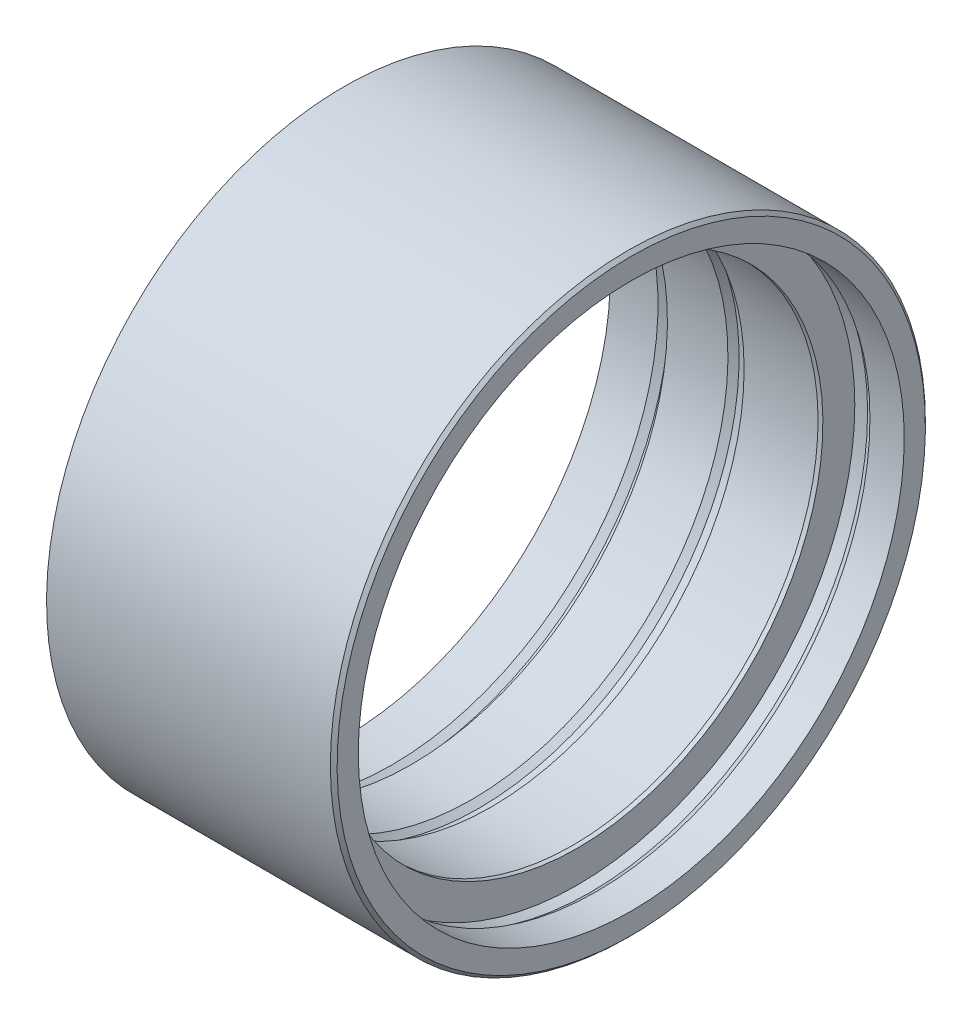
from build123d import *

# Parameters (mm, degrees)
ZKOSEN_1_SIZE = 0.5


with BuildPart() as part:
    # Skica2 → Rotovat1 (revolve)
    with BuildSketch(Plane.XY):
        Polygon((-36.713340937, -44.25), (6, -44.25), (6, -40.6), (0.9, -40.6), (-0.1, -41.25), (-2, -41.25), (-2, -36.5), (-2.716675115, -36.5), (-2.883909622, -37.600000008), (-14.813340937, -37.600000008), (-14.813340937, -38.75), (-16.713340937, -38.75), (-17.713340937, -38.094), (-26.713340937, -38.094), (-26.713340937, -40.25), (-28.613340937, -40.25), (-29.613340937, -39.594), (-36.713340937, -39.594), align=None)
    revolve(axis=Axis((0, 0, 0), (1, 0, 0)))

    # Zkosení1
    zkosen_1_edges = [part.edges().sort_by_distance(p)[0] for p in [
        (6, 44.25, 0),
    ]]
    chamfer(zkosen_1_edges, length=ZKOSEN_1_SIZE)


solid = part.part
